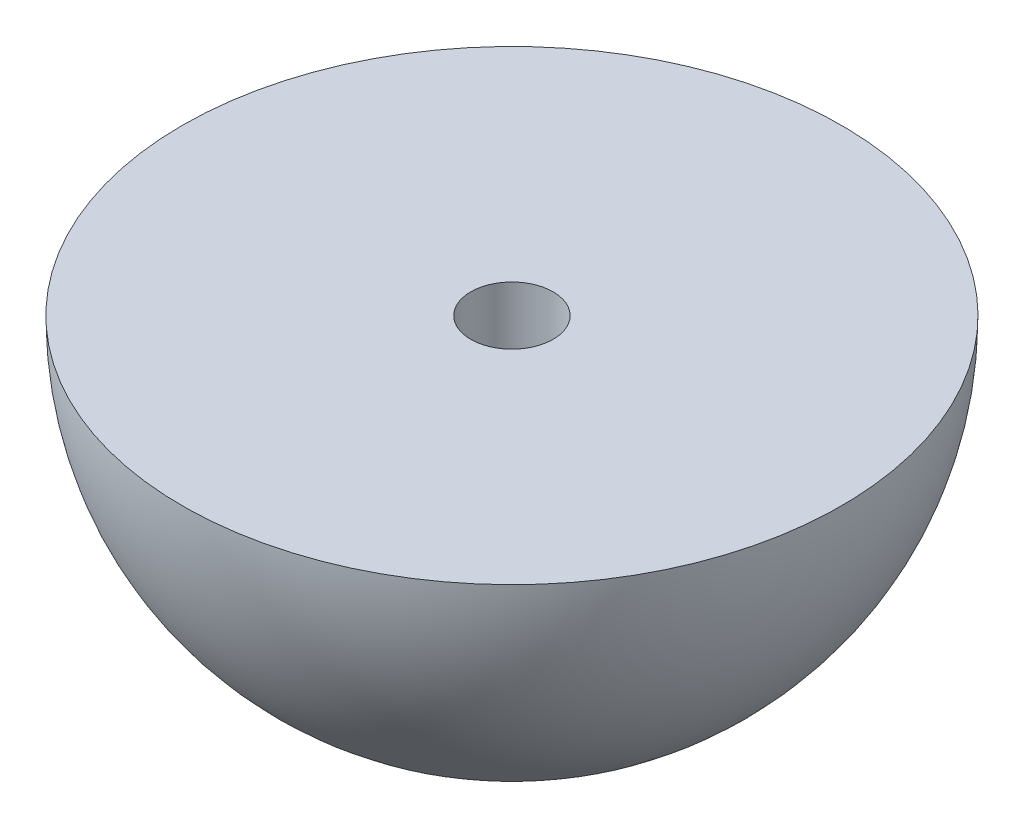
from build123d import *

# Parameters (mm, degrees)
ESQUISSE2_R             = 1
ENL_V_MAT_EXTRU_1_DEPTH = 9
ENL_V_MAT_EXTRU_3_DEPTH = 5.937253933


with BuildPart() as part:
    # Esquisse1 → Révolution1 (revolve)
    with BuildSketch(Plane.XY):
        with BuildLine():
            Line((-8, 0), (0, 0))
            Line((0, 0), (0, -8))
            ThreePointArc((0, -8), (-5.656854249, -5.656854249), (-8, 0))
        make_face()
    revolve(axis=Axis((0, 0, 0), (0, -1, 0)))

    # Esquisse2 → Enlèv. mat.-Extru.1 (cut, through all)
    with BuildSketch(Plane(origin=(0, 0, 0), x_dir=(1, 0, 0), z_dir=(0, 1, 0))):
        with Locations(Location((0, 0, 0), (0, 0, 180))):  # turned: the seam where the file's is
            Circle(ESQUISSE2_R)
    extrude(amount=-ENL_V_MAT_EXTRU_1_DEPTH, mode=Mode.SUBTRACT)

    # Esquisse4 → Enlèv. mat.-Extru.3 (cut, through all)
    with BuildSketch(Plane(origin=(0, -3, 0), x_dir=(1, 0, 0), z_dir=(0, 1, 0))):
        Polygon((2.16733828, -0.855303911), (1.824384055, 1.449318053), (-0.342954225, 2.304621965), (-2.16733828, 0.855303911), (-1.824384055, -1.449318053), (0.342954225, -2.304621965), align=None)
    extrude(amount=-ENL_V_MAT_EXTRU_3_DEPTH, mode=Mode.SUBTRACT)


solid = part.part
